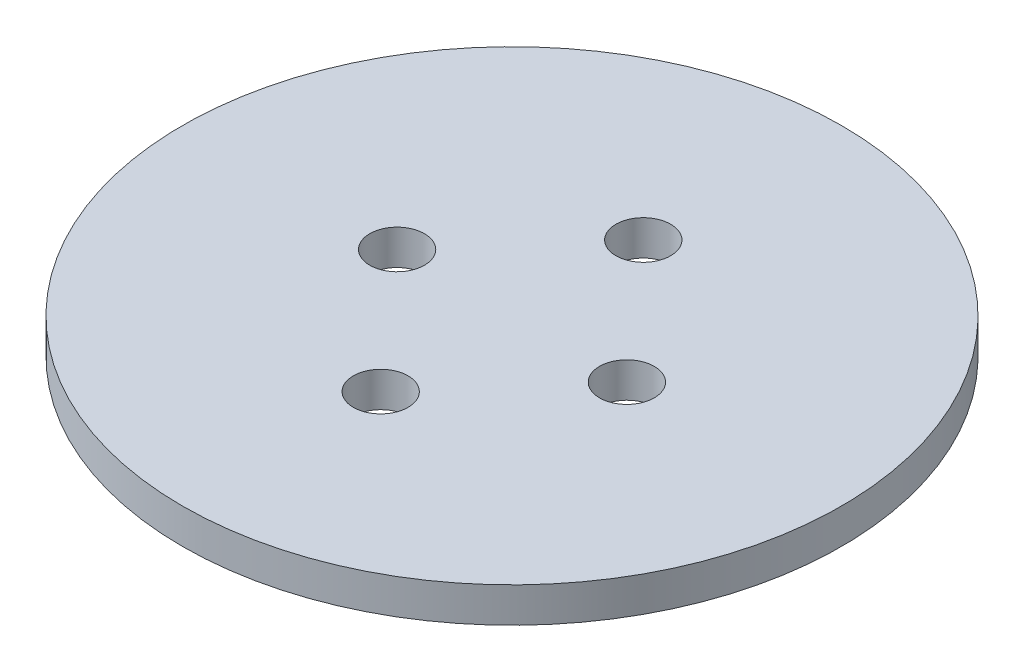
from build123d import *

# Parameters (mm, degrees)
SKETCH1_R            = 47.8155
BOSS_EXTRUDE1_DEPTH  = 5.08
U_BOLT_HOLES_D       = 7.9375
THREADED_ROD_HOLES_D = 7.9375


with BuildPart() as part:
    # Sketch1 → Boss-Extrude1 (new body)
    with BuildSketch(Plane(origin=(0, 0, 0), x_dir=(1, 0, 0), z_dir=(0, 1, 0))):
        Circle(SKETCH1_R)
    extrude(amount=BOSS_EXTRUDE1_DEPTH)

    # U-bolt Holes (through all)
    with Locations(Plane(origin=(0, 5.08, 0), x_dir=(1, 0, 0), z_dir=(0, 1, 0))):
        with Locations((-16.66875, 0), (16.66875, 0)):
            Hole(U_BOLT_HOLES_D / 2)

    # Threaded Rod Holes (through all)
    with Locations(Plane(origin=(0, 5.08, 0), x_dir=(1, 0, 0), z_dir=(0, 1, 0))):
        with Locations((0, 19.05), (0, -19.05)):
            Hole(THREADED_ROD_HOLES_D / 2)


solid = part.part
